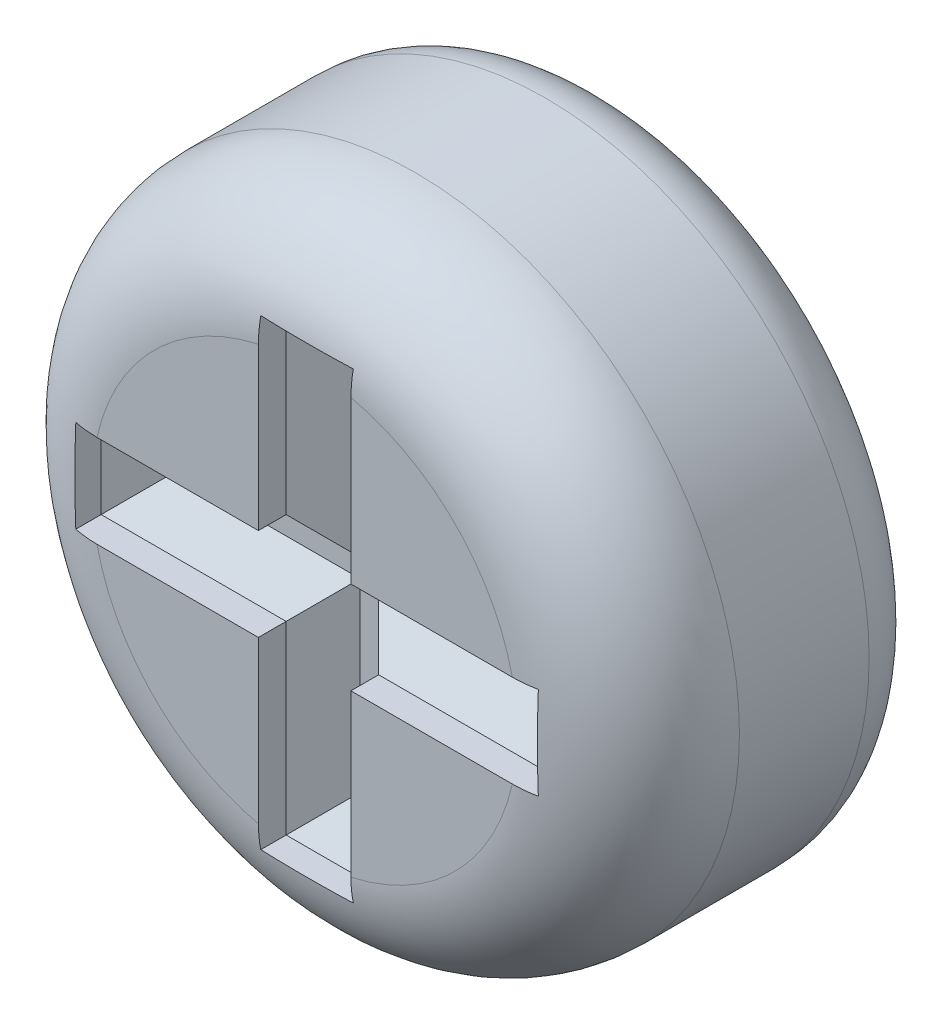
from build123d import *

# Parameters (mm, degrees)
SKETCH1_R          = 1.75
EXTRUDE1_DEPTH     = 1.651
FILLET1_R          = 0.6
CUT_EXTRUDE2_DEPTH = 0.35
CHAMFER1_SIZE      = 0.2
FILLET2_R          = 0.35


with BuildPart() as part:
    # Sketch1 → Extrude1 (new body)
    with BuildSketch(Plane.XY):
        Circle(SKETCH1_R)
    extrude(amount=EXTRUDE1_DEPTH)

    # Fillet1
    fillet1_edges = [part.edges().sort_by_distance(p)[0] for p in [
        (-1.75, 0, 1.651),
    ]]
    fillet(fillet1_edges, radius=FILLET1_R)

    # Sketch2 → Cut-Extrude2 (cut)
    with BuildSketch(Plane.XY.offset(1.651)):
        Polygon((0.25, -0.25), (0.25, -1.25), (-0.25, -1.25), (-0.25, -0.25), (-1.25, -0.25), (-1.25, 0.25), (-0.25, 0.25), (-0.25, 1.25), (0.25, 1.25), (0.25, 0.25), (1.25, 0.25), (1.25, -0.25), align=None)
    extrude(amount=-CUT_EXTRUDE2_DEPTH, mode=Mode.SUBTRACT)

    # Chamfer1
    chamfer1_edges = [part.edges().sort_by_distance(p)[0] for p in [
        (1.25, 0, 1.301),
        (0.75, 0.25, 1.301),
        (0.25, 0.75, 1.301),
        (0, 1.25, 1.301),
        (-0.25, 0.75, 1.301),
        (-0.75, 0.25, 1.301),
        (-1.25, 0, 1.301),
        (-0.75, -0.25, 1.301),
        (-0.25, -0.75, 1.301),
        (0, -1.25, 1.301),
        (0.25, -0.75, 1.301),
        (0.75, -0.25, 1.301),
    ]]
    chamfer(chamfer1_edges, length=CHAMFER1_SIZE)

    # Fillet2
    fillet2_edges = [part.edges().sort_by_distance(p)[0] for p in [
        (-1.75, 0, 0),
    ]]
    fillet(fillet2_edges, radius=FILLET2_R)


solid = part.part
